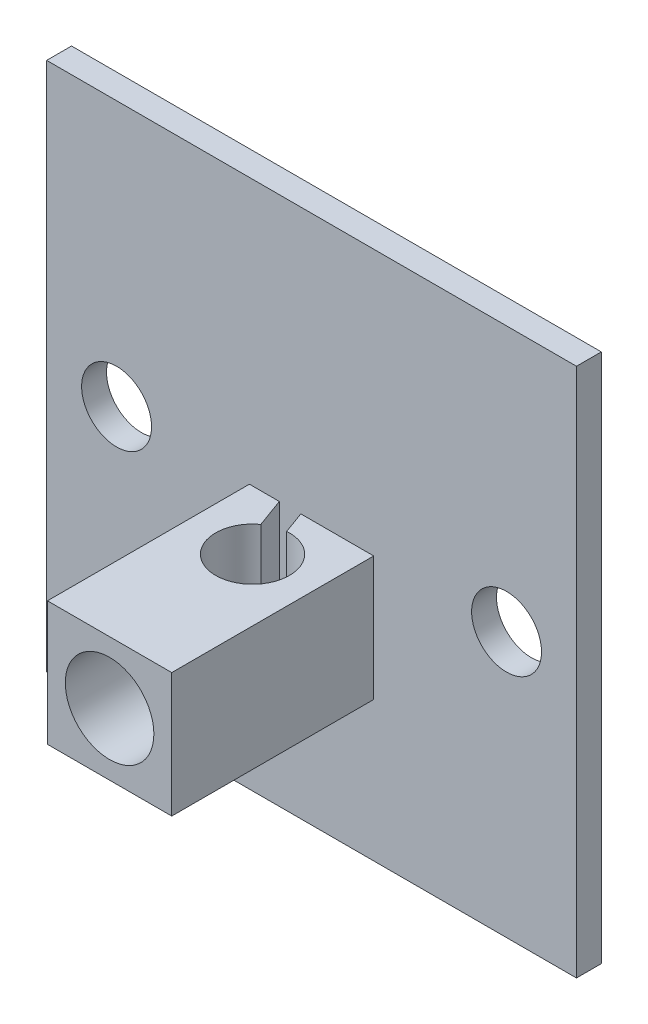
from build123d import *

# Parameters (mm, degrees)
SKETCH1_W           = 34.1
SKETCH1_H           = 34.1
SKETCH1_R           = 2.25
BOSS_EXTRUDE1_DEPTH = 1.6
SKETCH2_W           = 8
SKETCH2_H           = 17
BOSS_EXTRUDE2_DEPTH = 13
SKETCH12_R          = 2.375
CUT_EXTRUDE3_DEPTH  = 18
CUT_EXTRUDE4_DEPTH  = 12
SKETCH14_R          = 2.85
CUT_EXTRUDE9_DEPTH  = 5.7
CUT_EXTRUDE10_REACH = 10.9
SKETCH15_R          = 1.85
SKETCH19_W          = 13
SKETCH19_H          = 9
CUT_EXTRUDE11_DEPTH = 22.05


with BuildPart() as part:
    # Sketch1 → Boss-Extrude1 (new body)
    with BuildSketch(Plane.XY):
        Rectangle(SKETCH1_W, SKETCH1_H)
        with Locations((-12.55, 0)):
            Circle(SKETCH1_R, mode=Mode.SUBTRACT)
        with Locations((12.55, 0)):
            Circle(SKETCH1_R, mode=Mode.SUBTRACT)
    extrude(amount=BOSS_EXTRUDE1_DEPTH)

    # Sketch2 → Boss-Extrude2 (add)
    with BuildSketch(Plane.XY.offset(1.6)):
        with Locations((0, -8.55)):
            Rectangle(SKETCH2_W, SKETCH2_H)
    extrude(amount=BOSS_EXTRUDE2_DEPTH)

    # Sketch12 → Cut-Extrude3 (cut, through all)
    with BuildSketch(Plane(origin=(0, -0.05, 0), x_dir=(1, 0, 0), z_dir=(0, 1, 0))):
        with Locations((0, -5.4)):
            Circle(SKETCH12_R)
    extrude(amount=-CUT_EXTRUDE3_DEPTH, mode=Mode.SUBTRACT)

    # Sketch13 → Cut-Extrude4 (cut)
    with BuildSketch(Plane(origin=(0, -0.05, 0), x_dir=(1, 0, 0), z_dir=(0, 1, 0))):
        Polygon((-1.392084192, -3.475752978), (-2.074802442, -1.6), (-0.691371338, -1.6), (-0.170483785, -3.031126791), align=None)
    extrude(amount=-CUT_EXTRUDE4_DEPTH, mode=Mode.SUBTRACT)

    # Sketch14 → Cut-Extrude9 (cut)
    with BuildSketch(Plane.XY.offset(14.6)):
        with Locations((0, -12.55)):
            Circle(SKETCH14_R)
        with Locations((0, -4.05)):
            Circle(SKETCH14_R)
    extrude(amount=-CUT_EXTRUDE9_DEPTH, mode=Mode.SUBTRACT)

    # Sketch15 → Cut-Extrude10 (cut, up to next)
    with BuildSketch(Plane.XY.offset(8.9), mode=Mode.PRIVATE) as cut_extrude10_sk1:
        with Locations((0, -4.05)):
            Circle(SKETCH15_R)
    cut_extrude10_tool1 = extrude(cut_extrude10_sk1.sketch, amount=-CUT_EXTRUDE10_REACH, mode=Mode.PRIVATE) & part.part
    add(cut_extrude10_tool1.solids().sort_by_distance((0, -4.05, 8.9))[0], mode=Mode.SUBTRACT)
    # Sketch15 → Cut-Extrude10 (cut, up to next)
    with BuildSketch(Plane.XY.offset(8.9), mode=Mode.PRIVATE) as cut_extrude10_sk2:
        with Locations((0, -12.55)):
            Circle(SKETCH15_R)
    cut_extrude10_tool2 = extrude(cut_extrude10_sk2.sketch, amount=-CUT_EXTRUDE10_REACH, mode=Mode.PRIVATE) & part.part
    add(cut_extrude10_tool2.solids().sort_by_distance((0, -12.55, 8.9))[0], mode=Mode.SUBTRACT)

    # Sketch19 → Cut-Extrude11 (cut, through all)
    with BuildSketch(Plane.ZY.offset(4)):
        with Locations((8.1, -12.55)):
            Rectangle(SKETCH19_W, SKETCH19_H)
    extrude(amount=-CUT_EXTRUDE11_DEPTH, mode=Mode.SUBTRACT)


solid = part.part
